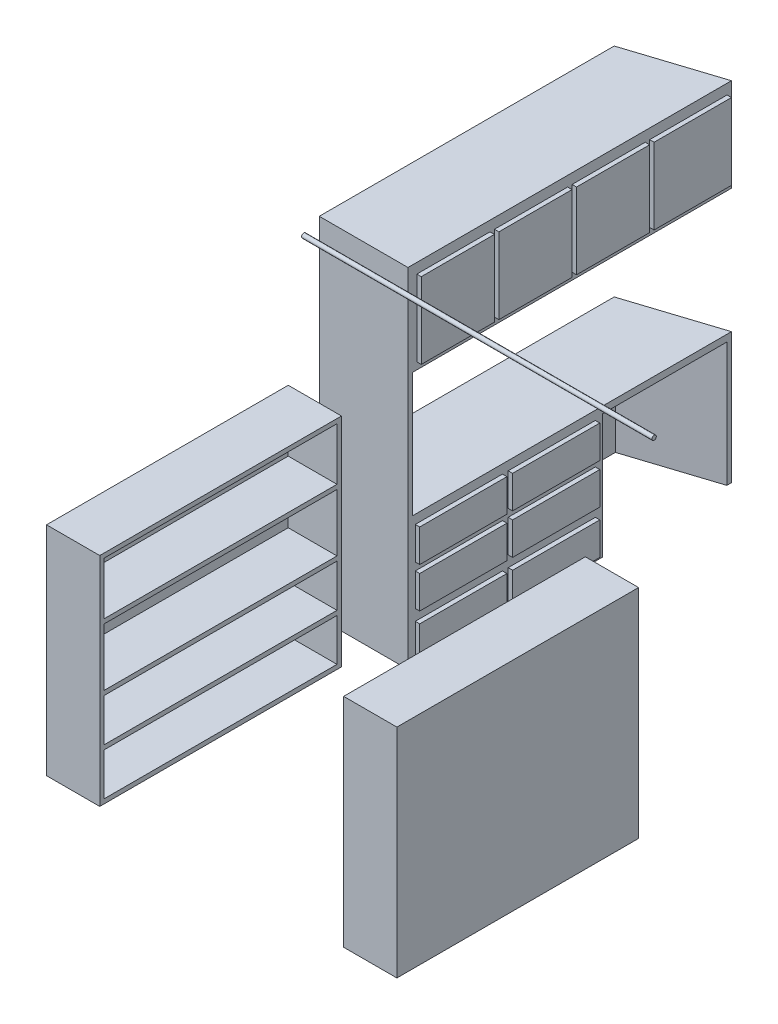
from build123d import *

# Parameters (mm, degrees)
SKETCH1_R            = 12.7
BOSS_EXTRUDE1_DEPTH  = 2006.6
BOSS_EXTRUDE2_DEPTH  = 38.1
SKETCH4_W            = 457.2
SKETCH4_H            = 1064.104668536
BOSS_EXTRUDE3_DEPTH  = 711.2
SKETCH5_W            = 499.288531824
SKETCH5_H            = 186.266666667
SKETCH5_H_2          = 186.182
BOSS_EXTRUDE4_DEPTH  = 25.4
SKETCH6_W            = 508
SKETCH6_H            = 25.4
BOSS_EXTRUDE5_DEPTH  = 1244.6
BOSS_EXTRUDE6_REACH  = 2886.719
SKETCH7_W            = 508
SKETCH7_H            = 533.4
SKETCH7_W_2          = 457.2
SKETCH7_H_2          = 482.6
SKETCH8_W            = 419.1
SKETCH8_H            = 435.424853887
SKETCH8_W_2          = 443.090744485
BOSS_EXTRUDE7_DEPTH  = 25.4
SKETCH9_W            = 304.8
SKETCH9_H            = 1384.3
BOSS_EXTRUDE8_DEPTH  = 25.4
BOSS_EXTRUDE9_DEPTH  = 1219.2
SKETCH11_W           = 1384.3
SKETCH11_H           = 25.4
BOSS_EXTRUDE10_DEPTH = 279.4


with BuildPart() as part:
    # Sketch1 → Boss-Extrude1 (new body)
    with BuildSketch(Plane.ZY.offset(-1003.3)):
        with Locations(Location((0, 1943.1, 0), (0, 0, 180))):
            Circle(SKETCH1_R)
    extrude(amount=BOSS_EXTRUDE1_DEPTH)


with BuildPart() as body_2:
    # Sketch3 → Boss-Extrude2 (new body)
    with BuildSketch(Plane(origin=(0, 711.2, 0), x_dir=(1, 0, 0), z_dir=(0, 1, 0))):
        Polygon((-495.3, 1941.690744485), (-1003.3, 1778), (-1003.3, 88.9), (-495.3, 88.9), align=None)
    extrude(amount=BOSS_EXTRUDE2_DEPTH)

    # Sketch4 → Boss-Extrude3 (add)
    with BuildSketch(Plane.XZ.offset(-711.2)):
        Polygon((-977.9, -1759.498461275), (-520.7, -1906.820131312), (-495.3, -1915.004668536), (-495.3, -1941.690744485), (-1003.3, -1778), (-1003.3, -88.9), (-495.3, -88.9), (-495.3, -1203.804668536), (-520.7, -1203.804668536), (-977.9, -1203.804668536), align=None)
        with Locations((-749.3, -646.352334268)):
            Rectangle(SKETCH4_W, SKETCH4_H, mode=Mode.SUBTRACT)
    extrude(amount=BOSS_EXTRUDE3_DEPTH)

    # Sketch5 → Boss-Extrude4 (add)
    with BuildSketch(Plane(origin=(-495.3, 0, 0), x_dir=(0, 0, -1), z_dir=(1, 0, 0))):
        with Locations((912.378501402, 605.366666667)):
            Rectangle(SKETCH5_W, SKETCH5_H)
        with Locations((380.326167134, 605.366666667)):
            Rectangle(SKETCH5_W, SKETCH5_H)
        with Locations((912.378501402, 124.883333333)):
            Rectangle(SKETCH5_W, SKETCH5_H_2)
        with Locations((380.326167134, 374.65)):
            Rectangle(SKETCH5_W, SKETCH5_H_2)
        with Locations((380.326167134, 124.883333333)):
            Rectangle(SKETCH5_W, SKETCH5_H_2)
        with Locations((912.378501402, 374.65)):
            Rectangle(SKETCH5_W, SKETCH5_H_2)
    extrude(amount=BOSS_EXTRUDE4_DEPTH)

    # Sketch6 → Boss-Extrude5 (add)
    with BuildSketch(Plane(origin=(0, 749.3, 0), x_dir=(1, 0, 0), z_dir=(0, 1, 0))):
        with Locations((-749.3, 101.6)):
            Rectangle(SKETCH6_W, SKETCH6_H)
    extrude(amount=BOSS_EXTRUDE5_DEPTH)

    # Boss-Extrude6: up to this plane
    boss_extrude6_end = Plane(origin=(-1003.3, 2019.3, -1778), z_dir=(0.306696917141153, 0, 0.9518072289156627))
    # Sketch7 → Boss-Extrude6 (add, up to the surface)
    with BuildSketch(Plane(origin=(0, 0, -114.3), x_dir=(-1, 0, 0), z_dir=(0, 0, -1)), mode=Mode.PRIVATE) as boss_extrude6_sk1:
        with Locations((749.3, 1727.2)):
            Rectangle(SKETCH7_W, SKETCH7_H)
        with Locations((749.3, 1727.2)):
            Rectangle(SKETCH7_W_2, SKETCH7_H_2, mode=Mode.SUBTRACT)
    boss_extrude6_tool1 = split(extrude(boss_extrude6_sk1.sketch, amount=BOSS_EXTRUDE6_REACH, mode=Mode.PRIVATE), bisect_by=boss_extrude6_end, keep=Keep.BOTH, mode=Mode.PRIVATE)
    add(boss_extrude6_tool1.solids().sort_by_distance((-749.3, 1986.534, -114.3))[0])

    # Sketch8 → Boss-Extrude7 (add)
    with BuildSketch(Plane(origin=(-495.3, 0, 0), x_dir=(0, 0, -1), z_dir=(1, 0, 0))):
        with Locations((349.25, 1718.020290396)):
            Rectangle(SKETCH8_W, SKETCH8_H)
        with Locations((793.75, 1718.020290396)):
            Rectangle(SKETCH8_W, SKETCH8_H)
        with Locations((1238.25, 1718.020290396)):
            Rectangle(SKETCH8_W, SKETCH8_H)
        with Locations((1694.745372243, 1718.020290396)):
            Rectangle(SKETCH8_W_2, SKETCH8_H)
    extrude(amount=BOSS_EXTRUDE7_DEPTH)


with BuildPart() as body_3:
    # Sketch9 → Boss-Extrude8 (new body)
    with BuildSketch(Plane(origin=(0, 0, 0), x_dir=(1, 0, 0), z_dir=(0, 1, 0))):
        with Locations((-850.9, -781.05)):
            Rectangle(SKETCH9_W, SKETCH9_H)
    extrude(amount=BOSS_EXTRUDE8_DEPTH)

    # Sketch10 → Boss-Extrude9 (add)
    with BuildSketch(Plane(origin=(0, 25.4, 0), x_dir=(1, 0, 0), z_dir=(0, 1, 0))):
        Polygon((-698.5, -114.3), (-977.9, -114.3), (-977.9, -1447.8), (-698.5, -1447.8), (-698.5, -1473.2), (-1003.3, -1473.2), (-1003.3, -88.9), (-698.5, -88.9), align=None)
    extrude(amount=BOSS_EXTRUDE9_DEPTH)

    # Sketch11 → Boss-Extrude10 (add)
    with BuildSketch(Plane(origin=(-977.9, 0, 0), x_dir=(0, 0, -1), z_dir=(1, 0, 0))):
        with Locations((-781.05, 1231.9)):
            Rectangle(SKETCH11_W, SKETCH11_H)
        with Locations((-781.05, 905.716093533)):
            Rectangle(SKETCH11_W, SKETCH11_H)
        with Locations((-781.05, 550.440690937)):
            Rectangle(SKETCH11_W, SKETCH11_H)
        with Locations((-781.05, 280.691778002)):
            Rectangle(SKETCH11_W, SKETCH11_H)
    extrude(amount=BOSS_EXTRUDE10_DEPTH)


with BuildPart() as body_4:
    # Mirror1: mirrored copy
    add(body_3.part.mirror(Plane(origin=(0, 0, 0), x_dir=(0, 0, 1), z_dir=(1, 0, 0))))


solid = Compound([part.part, body_2.part, body_3.part, body_4.part])
